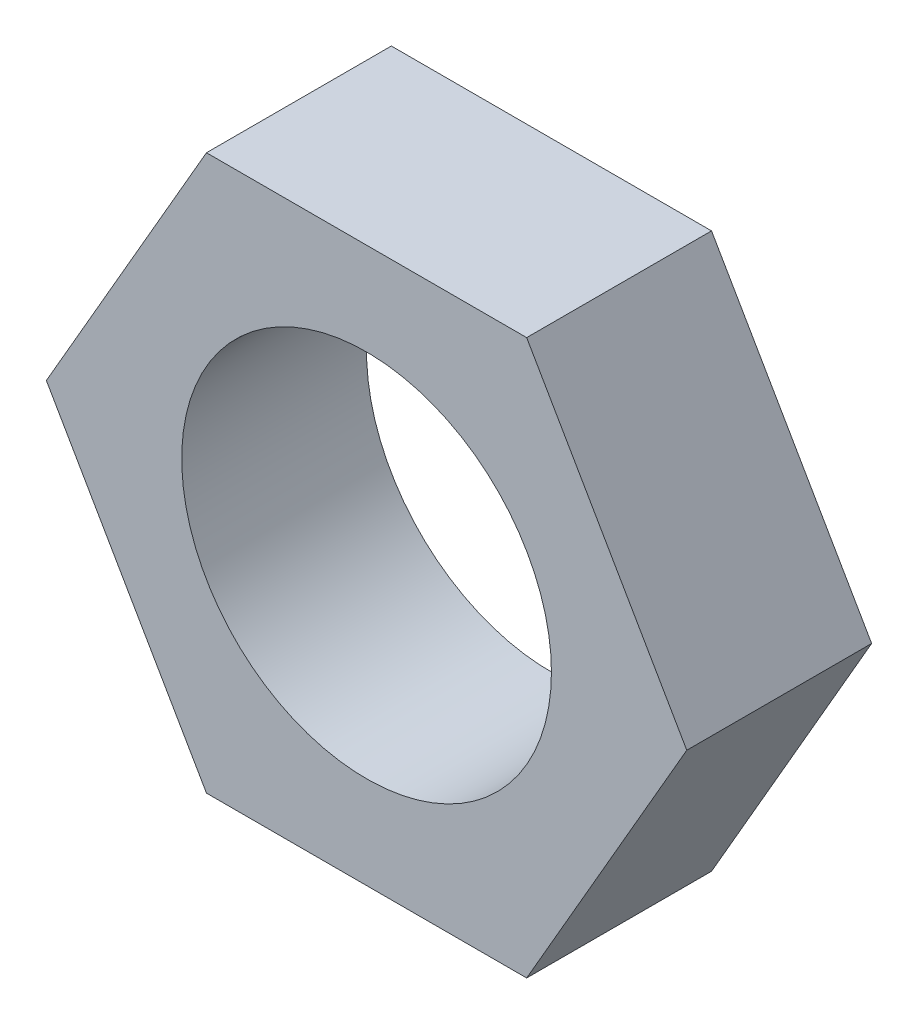
from build123d import *

# Parameters (mm, degrees)
SKETCH1_R           = 6.35
BOSS_EXTRUDE1_DEPTH = 6.35


with BuildPart() as part:
    # Sketch1 → Boss-Extrude1 (new body)
    with BuildSketch(Plane.XY):
        Polygon((5.499261314, -9.525), (10.998522628, 0), (5.499261314, 9.525), (-5.499261314, 9.525), (-10.998522628, 0), (-5.499261314, -9.525), align=None)
        Circle(SKETCH1_R, mode=Mode.SUBTRACT)
    extrude(amount=BOSS_EXTRUDE1_DEPTH)


solid = part.part
